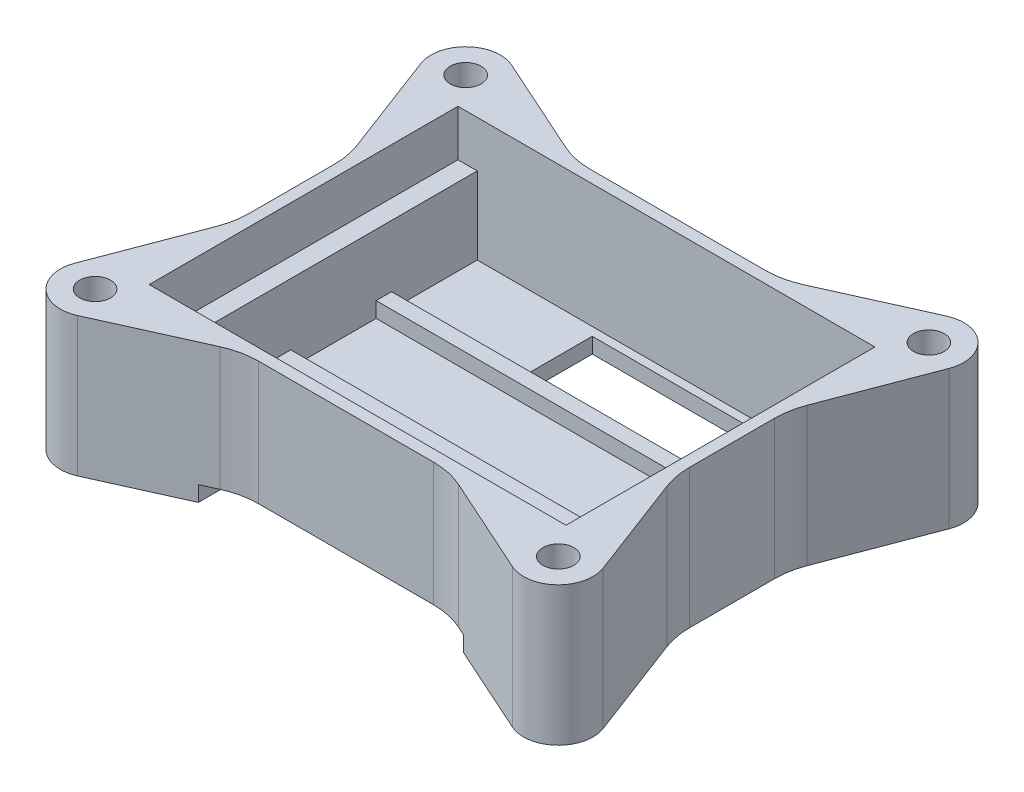
from build123d import *

# Parameters (mm, degrees)
SKETCH1_R           = 2
SKETCH1_W           = 57
SKETCH1_H           = 43
SKETCH1_W_2         = 54
SKETCH1_H_2         = 40
BOSS_EXTRUDE1_DEPTH = 18
SKETCH2_W           = 2.5
SKETCH2_H           = 40
SKETCH2_W_2         = 4
BOSS_EXTRUDE2_DEPTH = 12
SKETCH3_W           = 54
SKETCH3_H           = 40
SKETCH3_W_2         = 40
SKETCH3_H_2         = 8.5
SKETCH3_W_3         = 23
SKETCH3_W_4         = 3.5
BOSS_EXTRUDE3_DEPTH = 2
SKETCH4_W           = 1.5
SKETCH4_H           = 5
CUT_EXTRUDE1_DEPTH  = 1
BOSS_EXTRUDE4_REACH = 59.5
SKETCH5_W           = 2
SKETCH5_H           = 2
FILLET1_R           = 10
CUT_EXTRUDE2_START  = -5.35
SKETCH6_W           = 34
SKETCH6_H           = 2
CUT_EXTRUDE2_DEPTH  = 7.103529


with BuildPart() as part:
    # Sketch1 → Boss-Extrude1 (new body)
    with BuildSketch(Plane(origin=(0, 0, 0), x_dir=(1, 0, 0), z_dir=(0, 1, 0))):
        with BuildLine():
            Line((-28.5, 7.357542402), (-28.5, 21.5))
            Line((-28.5, 21.5), (-13.47815401, 21.5))
            Line((-13.47815401, 21.5), (-28.153404403, 28.103667226))
            ThreePointArc((-28.153404403, 28.103667226), (-33.084632617, 27.276437336), (-34.207471192, 22.404009346))
            Line((-34.207471192, 22.404009346), (-28.5, 7.357542402))
        make_face()
        with Locations((-30, 24)):
            Circle(SKETCH1_R, mode=Mode.SUBTRACT)
        with BuildLine():
            Line((-28.5, -21.5), (-28.5, -7.357542402))
            Line((-28.5, -7.357542402), (-34.207471192, -22.404009346))
            ThreePointArc((-34.207471192, -22.404009346), (-33.084632617, -27.276437336), (-28.153404403, -28.103667226))
            Line((-28.153404403, -28.103667226), (-13.47815401, -21.5))
            Line((-13.47815401, -21.5), (-28.5, -21.5))
        make_face()
        with Locations((-30, -24)):
            Circle(SKETCH1_R, mode=Mode.SUBTRACT)
        Rectangle(SKETCH1_W, SKETCH1_H)
        Rectangle(SKETCH1_W_2, SKETCH1_H_2, mode=Mode.SUBTRACT)
        with BuildLine():
            Line((34.207471192, -22.404009346), (28.5, -7.357542402))
            Line((28.5, -7.357542402), (28.5, -21.5))
            Line((28.5, -21.5), (13.47815401, -21.5))
            Line((13.47815401, -21.5), (28.153404403, -28.103667226))
            ThreePointArc((28.153404403, -28.103667226), (33.084632617, -27.276437336), (34.207471192, -22.404009346))
        make_face()
        with Locations((30, -24)):
            Circle(SKETCH1_R, mode=Mode.SUBTRACT)
        with BuildLine():
            Line((28.153404403, 28.103667226), (13.47815401, 21.5))
            Line((13.47815401, 21.5), (28.5, 21.5))
            Line((28.5, 21.5), (28.5, 7.357542402))
            Line((28.5, 7.357542402), (34.207471192, 22.404009346))
            ThreePointArc((34.207471192, 22.404009346), (33.084632617, 27.276437336), (28.153404403, 28.103667226))
        make_face()
        with Locations((30, 24)):
            Circle(SKETCH1_R, mode=Mode.SUBTRACT)
    extrude(amount=BOSS_EXTRUDE1_DEPTH)

    # Sketch2 → Boss-Extrude2 (add)
    with BuildSketch(Plane(origin=(0, 0, 0), x_dir=(1, 0, 0), z_dir=(0, 1, 0))):
        with Locations((-25.75, 0)):
            Rectangle(SKETCH2_W, SKETCH2_H)
        with Locations((25, 0)):
            Rectangle(SKETCH2_W_2, SKETCH2_H)
    extrude(amount=BOSS_EXTRUDE2_DEPTH)

    # Sketch3 → Boss-Extrude3 (add)
    with BuildSketch(Plane(origin=(0, 0, 0), x_dir=(1, 0, 0), z_dir=(0, 1, 0))):
        Rectangle(SKETCH3_W, SKETCH3_H)
        with Locations((-0.375, -11.9)):
            Rectangle(SKETCH3_W_2, SKETCH3_H_2, mode=Mode.SUBTRACT)
        with Locations((3, 14.65)):
            Rectangle(SKETCH3_W_3, SKETCH3_H_2, mode=Mode.SUBTRACT)
        with Locations((17.5, 14.65)):
            Rectangle(SKETCH3_W_4, SKETCH3_H_2, mode=Mode.SUBTRACT)
    extrude(amount=BOSS_EXTRUDE3_DEPTH)

    # Sketch4 → Cut-Extrude1 (cut)
    with BuildSketch(Plane.XZ):
        Polygon((-10, -17.9), (-10, -19.4), (-12, -19.4), (-12, -21.4), (-13.5, -21.4), (-13.5, -19.4), (-15.5, -19.4), (-15.5, -17.9), (-13.5, -17.9), (-13.5, -15.9), (-12, -15.9), (-12, -17.9), align=None)
        with Locations((-12.75, -10.9)):
            Rectangle(SKETCH4_W, SKETCH4_H)
    extrude(amount=-CUT_EXTRUDE1_DEPTH, mode=Mode.SUBTRACT)

    # Sketch5 → Boss-Extrude4 (add, up to next)
    with BuildSketch(Plane.ZY.offset(-23), mode=Mode.PRIVATE) as boss_extrude4_sk1:
        with Locations((5.15, 3)):
            Rectangle(SKETCH5_W, SKETCH5_H)
    boss_extrude4_tool1 = extrude(boss_extrude4_sk1.sketch, amount=BOSS_EXTRUDE4_REACH, mode=Mode.PRIVATE) - part.part
    add(boss_extrude4_tool1.solids().sort_by_distance((23, 3, 5.15))[0])
    # Sketch5 → Boss-Extrude4 (add, up to next)
    with BuildSketch(Plane.ZY.offset(-23), mode=Mode.PRIVATE) as boss_extrude4_sk2:
        with Locations((-7.9, 3)):
            Rectangle(SKETCH5_W, SKETCH5_H)
    boss_extrude4_tool2 = extrude(boss_extrude4_sk2.sketch, amount=BOSS_EXTRUDE4_REACH, mode=Mode.PRIVATE) - part.part
    add(boss_extrude4_tool2.solids().sort_by_distance((23, 3, -7.9))[0])

    # Fillet1
    fillet1_edges = [part.edges().sort_by_distance(p)[0] for p in [
        (28.5, 9, 7.357542402),
        (13.47815401, 9, 21.5),
        (-13.47815401, 9, 21.5),
        (-28.5, 9, 7.357542402),
        (-28.5, 9, -7.357542402),
        (-13.47815401, 9, -21.5),
        (13.47815401, 9, -21.5),
        (28.5, 9, -7.357542402),
    ]]
    fillet(fillet1_edges, radius=FILLET1_R)

    # Sketch6 → Cut-Extrude2 (cut)
    with BuildSketch(Plane.XY.offset(21.5).offset(CUT_EXTRUDE2_START)):
        with Locations((-0.375, 1)):
            Rectangle(SKETCH6_W, SKETCH6_H)
    extrude(amount=CUT_EXTRUDE2_DEPTH, mode=Mode.SUBTRACT)


solid = part.part
